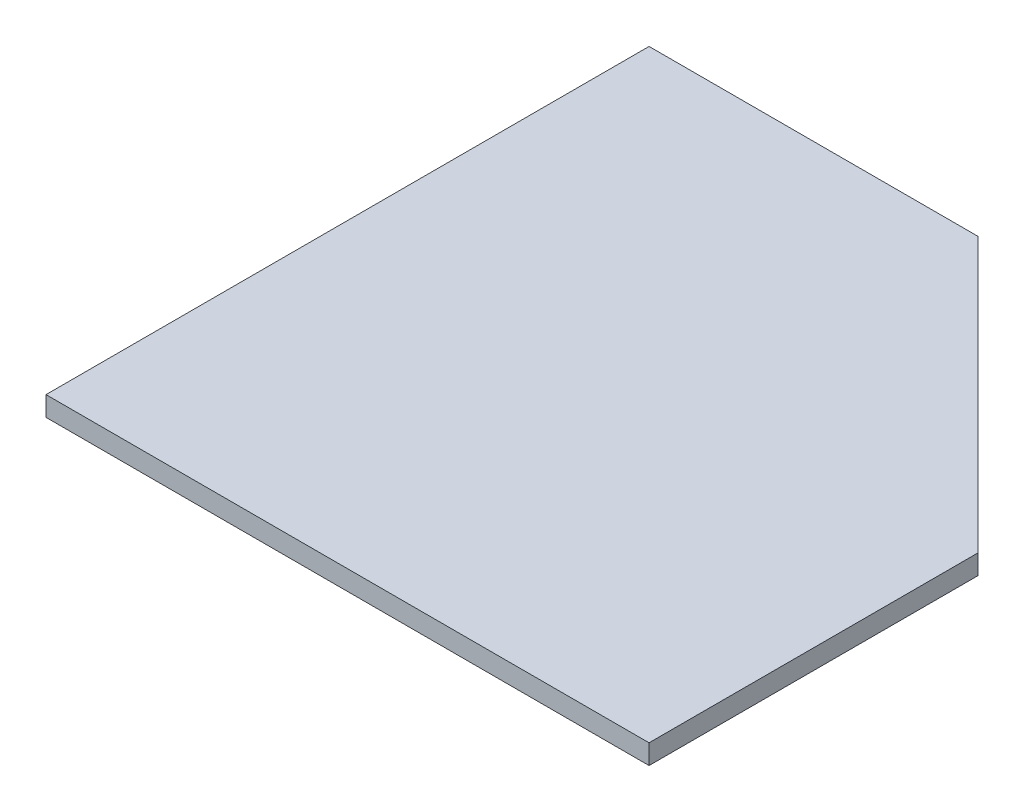
from build123d import *

# Parameters (mm, degrees)
EXTRUDE_1_DEPTH = 18


with BuildPart() as part:
    # Эскиз1 → Бобышка-Вытянуть1 (new body)
    with BuildSketch(Plane(origin=(0, 0, 0), x_dir=(1, 0, 0), z_dir=(0, 1, 0))):
        Polygon((0, 0), (0, 550), (300, 550), (550, 300), (550, 0), align=None)
    extrude(amount=EXTRUDE_1_DEPTH)


solid = part.part
